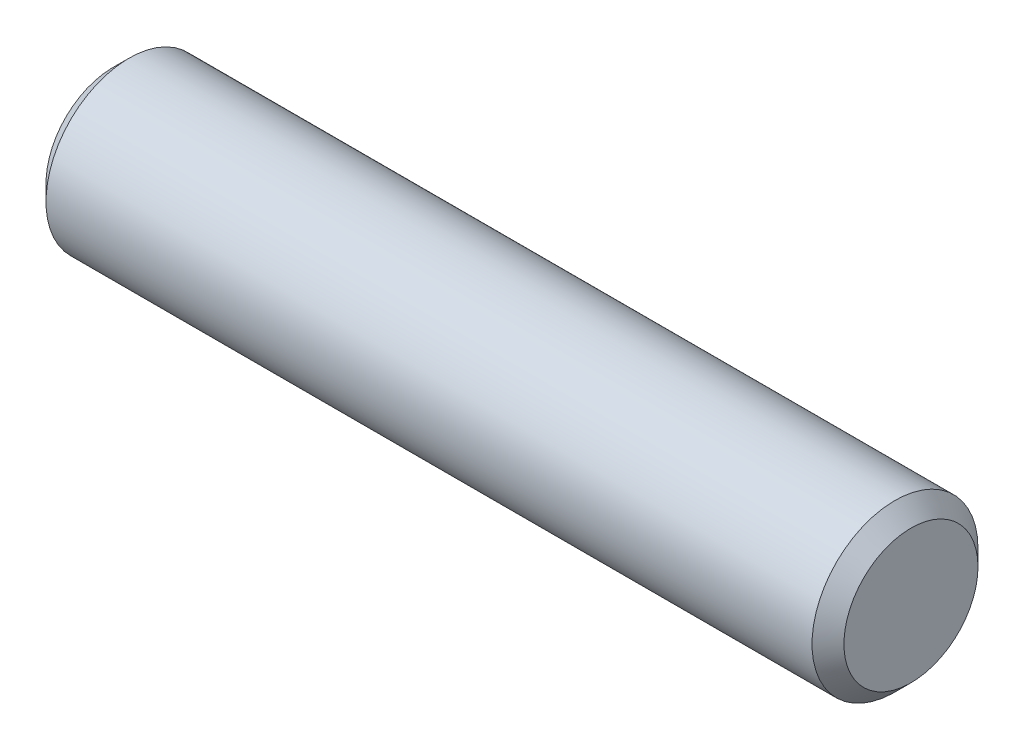
from build123d import *

# Parameters (mm, degrees)
SKETCH1_R           = 7.9248
BOSS_EXTRUDE1_DEPTH = 38.1
CHAMFER1_SIZE       = 1.524
CHAMFER2_SIZE       = 1.524


with BuildPart() as part:
    # Sketch1 → Boss-Extrude1 (new body, symmetric)
    with BuildSketch(Plane(origin=(0, 0, 0), x_dir=(0, 0, -1), z_dir=(1, 0, 0))):
        Circle(SKETCH1_R)
    extrude(amount=BOSS_EXTRUDE1_DEPTH, both=True)

    # Chamfer1
    chamfer1_edges = [part.edges().sort_by_distance(p)[0] for p in [
        (38.1, 0, 7.9248),
    ]]
    chamfer(chamfer1_edges, length=CHAMFER1_SIZE)

    # Chamfer2
    chamfer2_edges = [part.edges().sort_by_distance(p)[0] for p in [
        (-38.1, 0, 7.9248),
    ]]
    chamfer(chamfer2_edges, length=CHAMFER2_SIZE)


solid = part.part
